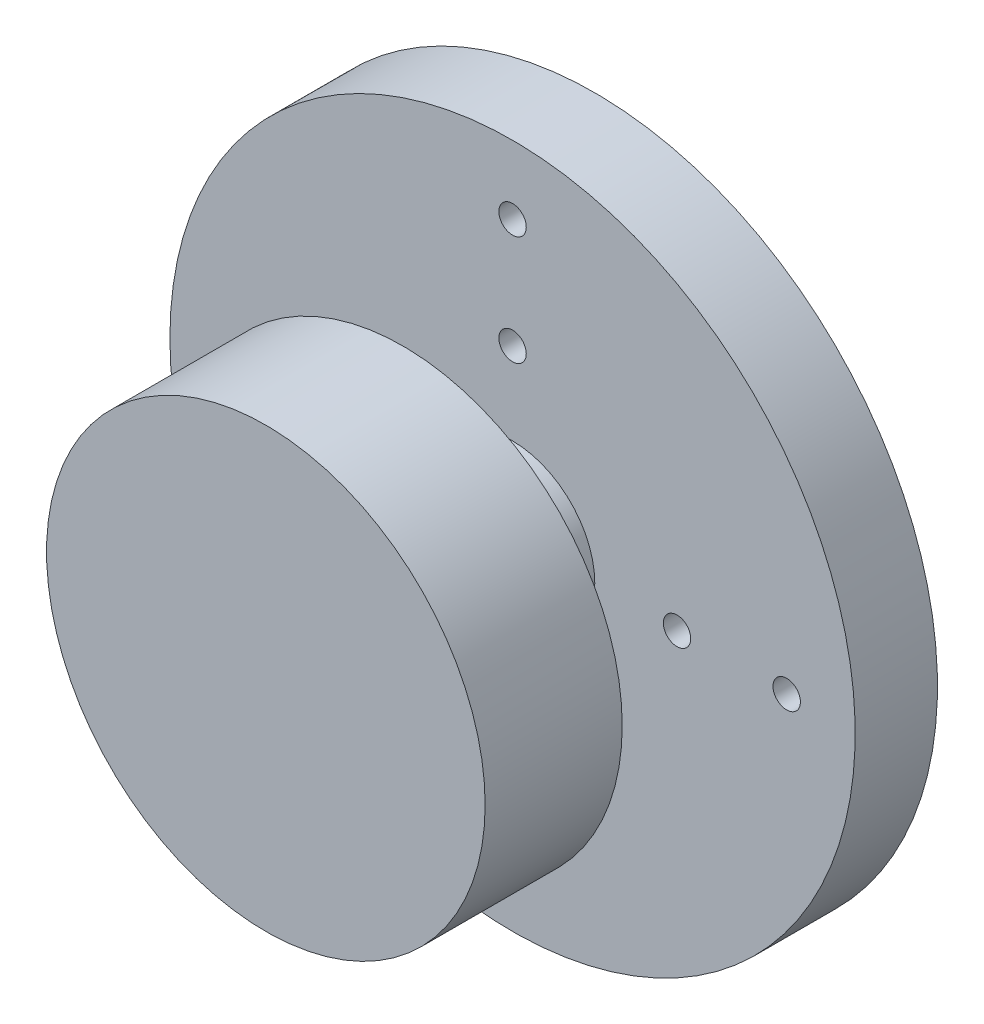
from build123d import *

# Parameters (mm, degrees)
SKETCH1_R          = 8
EXTRUDE1_DEPTH     = 5
SKETCH2_R          = 3
EXTRUDE2_DEPTH     = 4
SKETCH3_R          = 12.5
EXTRUDE3_DEPTH     = 3
SKETCH4_R          = 0.5
CUT_EXTRUDE1_DEPTH = 4
CIRPATTERN1_COUNT  = 4


with BuildPart() as part:
    # Sketch1 → Extrude1 (new body)
    with BuildSketch(Plane.XY):
        Circle(SKETCH1_R)
    extrude(amount=EXTRUDE1_DEPTH)

    # Sketch2 → Extrude2 (add)
    with BuildSketch(Plane(origin=(0, 0, 0), x_dir=(-1, 0, 0), z_dir=(0, 0, -1))):
        with Locations(Location((0, 0, 0), (0, 0, 180))):  # turned: the seam where the file's is
            Circle(SKETCH2_R)
    extrude(amount=EXTRUDE2_DEPTH)

    # Sketch3 → Extrude3 (add)
    with BuildSketch(Plane(origin=(0, 0, -4), x_dir=(-1, 0, 0), z_dir=(0, 0, -1))):
        Circle(SKETCH3_R)
    extrude(amount=EXTRUDE3_DEPTH)

    # Sketch4 → Cut-Extrude1 (cut, through all)
    with BuildSketch(Plane.XY.offset(-4)):
        with Locations((0, 6)):
            Circle(SKETCH4_R)
        with Locations((0, 10)):
            Circle(SKETCH4_R)
    cut_extrude1 = extrude(amount=-CUT_EXTRUDE1_DEPTH, mode=Mode.SUBTRACT)

    # CirPattern1: Cut-Extrude1 ×4 about axis
    cirpattern1_axis = Axis((0, 0, 0), (0, 0, 1))
    for i in range(1, CIRPATTERN1_COUNT):
        add(cut_extrude1.rotate(cirpattern1_axis, i * 360 / CIRPATTERN1_COUNT), mode=Mode.SUBTRACT)


solid = part.part
